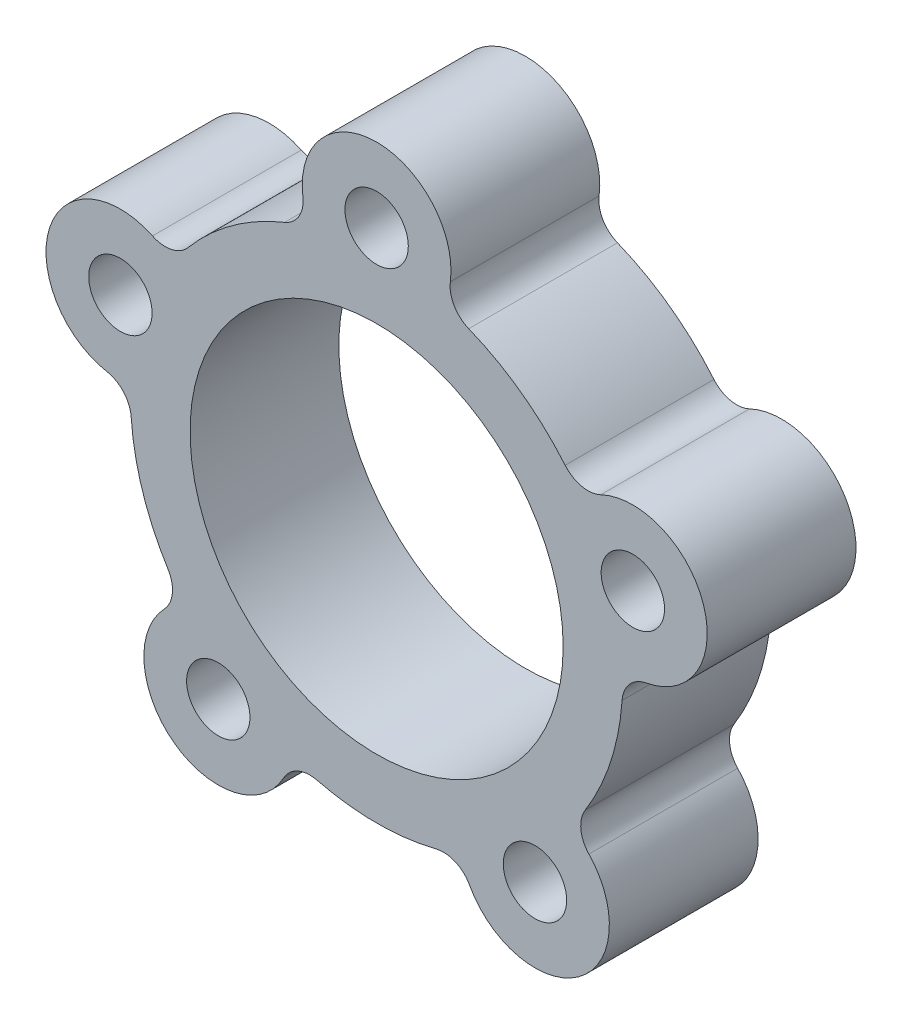
from build123d import *

# Parameters (mm, degrees)
SKETCH1_R             = 7.9629
BOSS_EXTRUDE1_DEPTH   = 6.35
F_6_32_TAPPED_HOLE1_D = 2.7051


with BuildPart() as part:
    # Sketch1 → Boss-Extrude1 (new body)
    with BuildSketch(Plane.XY.offset(7.874)):
        with BuildLine():
            ThreePointArc((8.047909304, 6.74848607), (6.173449726, 8.49702459), (3.931250908, 9.739413469))
            ThreePointArc((3.931250908, 9.739413469), (3.309450684, 10.277458281), (3.147581267, 11.08363818))
            ThreePointArc((3.147581267, 11.08363818), (0, 14.675), (-3.147581267, 11.08363818))
            ThreePointArc((-3.147581267, 11.08363818), (-3.309450684, 10.277458281), (-3.931250908, 9.739413469))
            ThreePointArc((-3.931250908, 9.739413469), (-6.173449726, 8.49702459), (-8.047909304, 6.74848607))
            ThreePointArc((-8.047909304, 6.74848607), (-8.751767166, 6.323383906), (-9.568510213, 6.418560232))
            ThreePointArc((-9.568510213, 6.418560232), (-13.956754377, 4.534824392), (-11.513822419, 0.431504882))
            ThreePointArc((-11.513822419, 0.431504882), (-10.797120172, 0.028434629), (-10.477555984, -0.729197516))
            ThreePointArc((-10.477555984, -0.729197516), (-9.988851485, -3.24557459), (-8.905132396, -5.568619705))
            ThreePointArc((-8.905132396, -5.568619705), (-8.718340254, -6.369392103), (-9.061245801, -7.116749798))
            ThreePointArc((-9.061245801, -7.116749798), (-8.625748577, -11.872324392), (-3.968352328, -10.816953497))
            ThreePointArc((-3.968352328, -10.816953497), (-3.363536563, -10.259884713), (-2.544234809, -10.190082318))
            ThreePointArc((-2.544234809, -10.190082318), (0, -10.5029), (2.544234809, -10.190082318))
            ThreePointArc((2.544234809, -10.190082318), (3.363536563, -10.259884713), (3.968352328, -10.816953497))
            ThreePointArc((3.968352328, -10.816953497), (8.625748577, -11.872324392), (9.061245801, -7.116749798))
            ThreePointArc((9.061245801, -7.116749798), (8.718340254, -6.369392103), (8.905132396, -5.568619705))
            ThreePointArc((8.905132396, -5.568619705), (9.988851485, -3.24557459), (10.477555984, -0.729197516))
            ThreePointArc((10.477555984, -0.729197516), (10.797120172, 0.028434629), (11.513822419, 0.431504882))
            ThreePointArc((11.513822419, 0.431504882), (13.956754377, 4.534824392), (9.568510213, 6.418560232))
            ThreePointArc((9.568510213, 6.418560232), (8.751767166, 6.323383906), (8.047909304, 6.74848607))
        make_face()
        Circle(SKETCH1_R, mode=Mode.SUBTRACT)
    extrude(amount=BOSS_EXTRUDE1_DEPTH)

    # #6-32 Tapped Hole1 (through all)
    with Locations(Plane.XY.offset(14.224)):
        with Locations((-10.937149937, 3.553695435), (0, 11.5), (10.937149937, 3.553695435), (6.759530401, -9.303695435), (-6.759530401, -9.303695435)):
            Hole(F_6_32_TAPPED_HOLE1_D / 2)


solid = part.part
